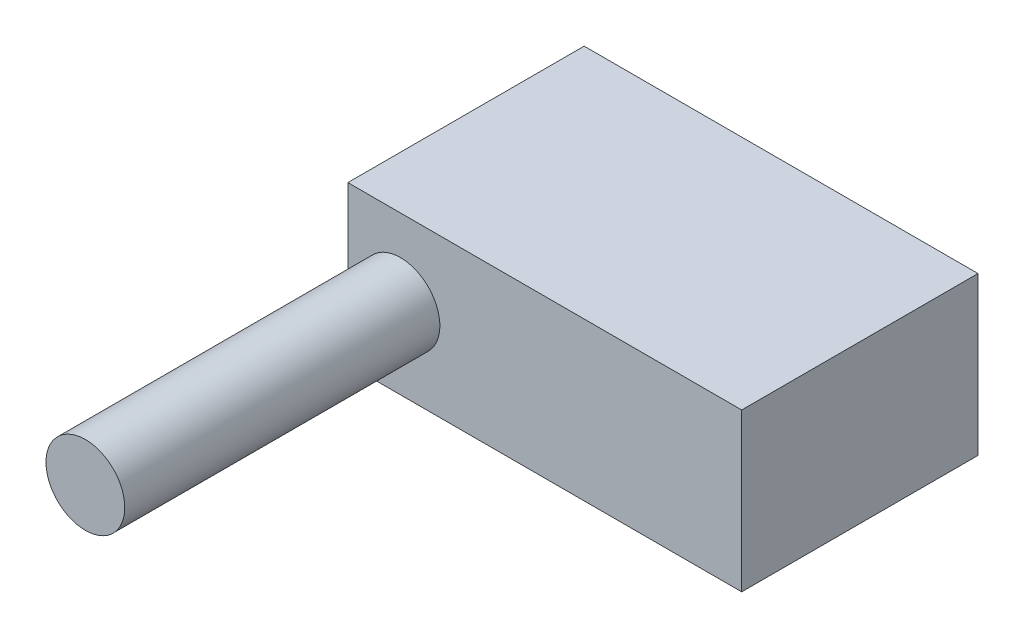
from build123d import *

# Parameters (mm, degrees)
SKETCH2_W           = 50
SKETCH2_H           = 30
BOSS_EXTRUDE1_DEPTH = 20
SKETCH3_R           = 5
BOSS_EXTRUDE2_DEPTH = 40


with BuildPart() as part:
    # Sketch2 → Boss-Extrude1 (new body)
    with BuildSketch(Plane(origin=(0, 0, 0), x_dir=(1, 0, 0), z_dir=(0, 1, 0))):
        Rectangle(SKETCH2_W, SKETCH2_H)
    extrude(amount=BOSS_EXTRUDE1_DEPTH)

    # Sketch3 → Boss-Extrude2 (add)
    with BuildSketch(Plane.XY.offset(15)):
        with Locations((-18.321291678, 10.095867224)):
            Circle(SKETCH3_R)
    extrude(amount=BOSS_EXTRUDE2_DEPTH)


solid = part.part
